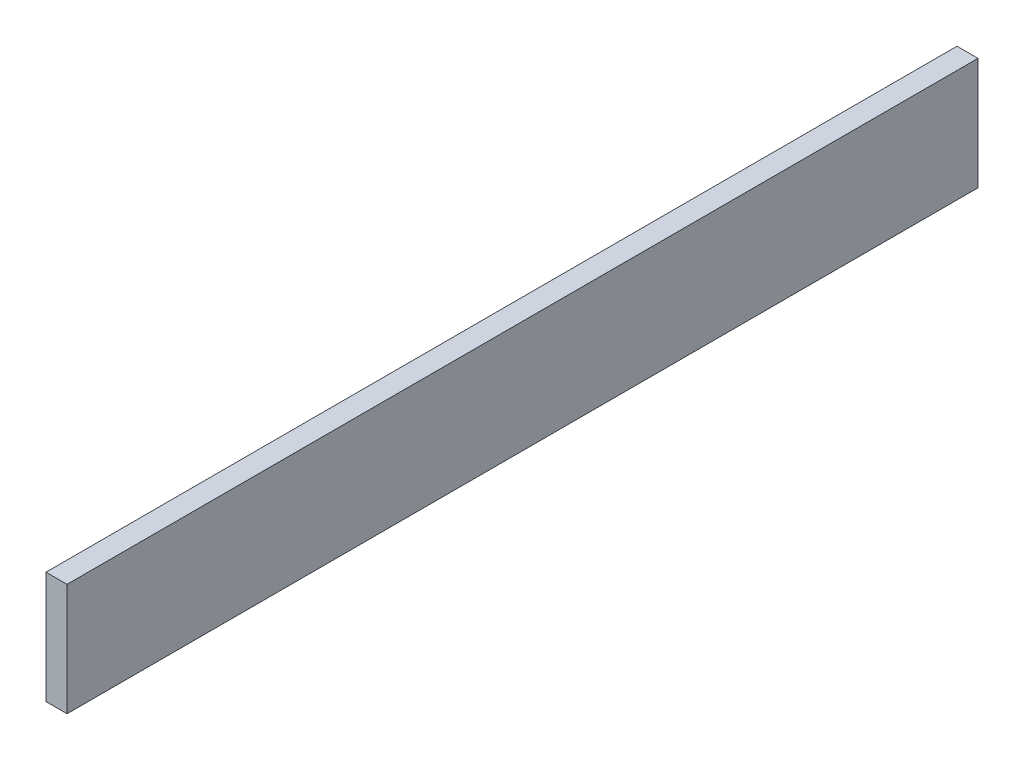
from build123d import *

# Parameters (mm, degrees)
SKETCH1_W           = 130
SKETCH1_H           = 16
BOSS_EXTRUDE1_DEPTH = 3


with BuildPart() as part:
    # Sketch1 → Boss-Extrude1 (new body)
    with BuildSketch(Plane(origin=(0, 0, 0), x_dir=(0, 0, -1), z_dir=(1, 0, 0))):
        with Locations((43.458474949, 4.951355796)):
            Rectangle(SKETCH1_W, SKETCH1_H)
    extrude(amount=BOSS_EXTRUDE1_DEPTH)


solid = part.part
